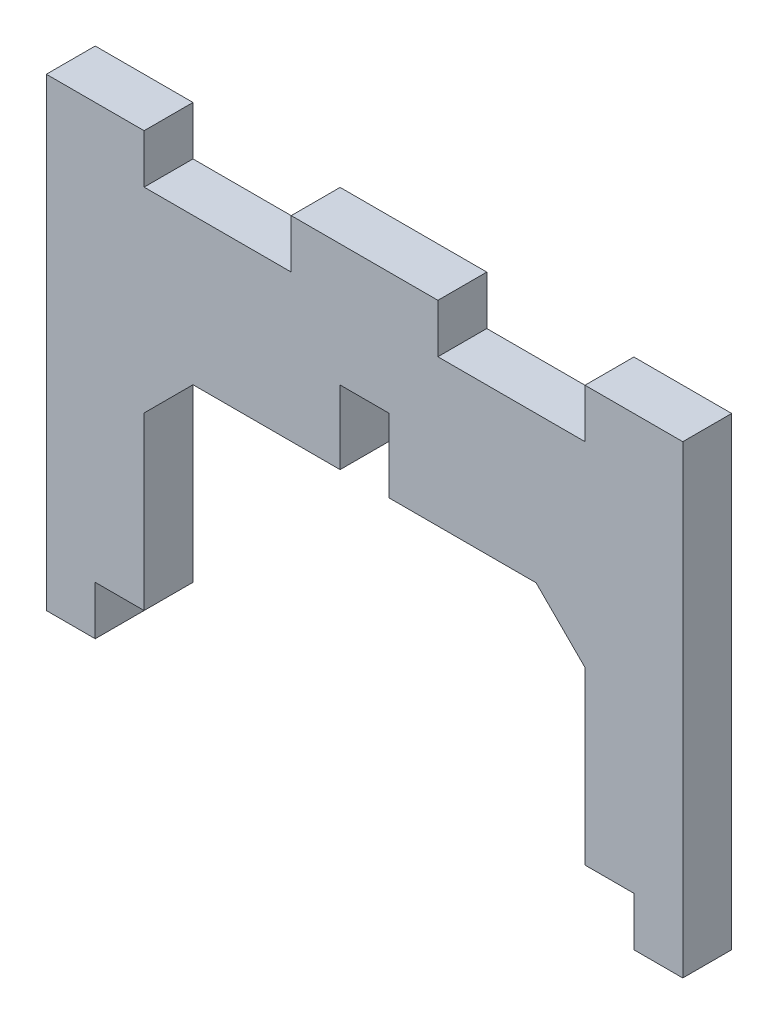
from build123d import *

# Parameters (mm, degrees)
BOSS_EXTRUDE1_DEPTH = 4
CHAMFER1_SIZE       = 4
SKETCH2_W           = 8
SKETCH2_H           = 4
SKETCH2_W_2         = 12
BOSS_EXTRUDE2_DEPTH = 4


with BuildPart() as part:
    # Sketch1 → Boss-Extrude1 (new body)
    with BuildSketch(Plane.XY):
        Polygon((0, 34), (0, 0), (4, 0), (4, 4), (8, 4), (8, 22), (24.035, 22), (24.035, 28), (26.035, 28), (26.035, 34), align=None)
        Polygon((52.07, 34), (26.035, 34), (26.035, 28), (28.035, 28), (28.035, 22), (44.07, 22), (44.07, 4), (48.07, 4), (48.07, 0), (52.07, 0), align=None)
    extrude(amount=BOSS_EXTRUDE1_DEPTH)

    # Chamfer1
    chamfer1_edges = [part.edges().sort_by_distance(p)[0] for p in [
        (44.07, 22, 2),
        (8, 22, 2),
    ]]
    chamfer(chamfer1_edges, length=CHAMFER1_SIZE)

    # Sketch2 → Boss-Extrude2 (add)
    with BuildSketch(Plane.XY.offset(4)):
        with Locations((4, 36)):
            Rectangle(SKETCH2_W, SKETCH2_H)
        with Locations((48.07, 36)):
            Rectangle(SKETCH2_W, SKETCH2_H)
        with Locations((26.035, 36)):
            Rectangle(SKETCH2_W_2, SKETCH2_H)
    extrude(amount=-BOSS_EXTRUDE2_DEPTH)


solid = part.part
